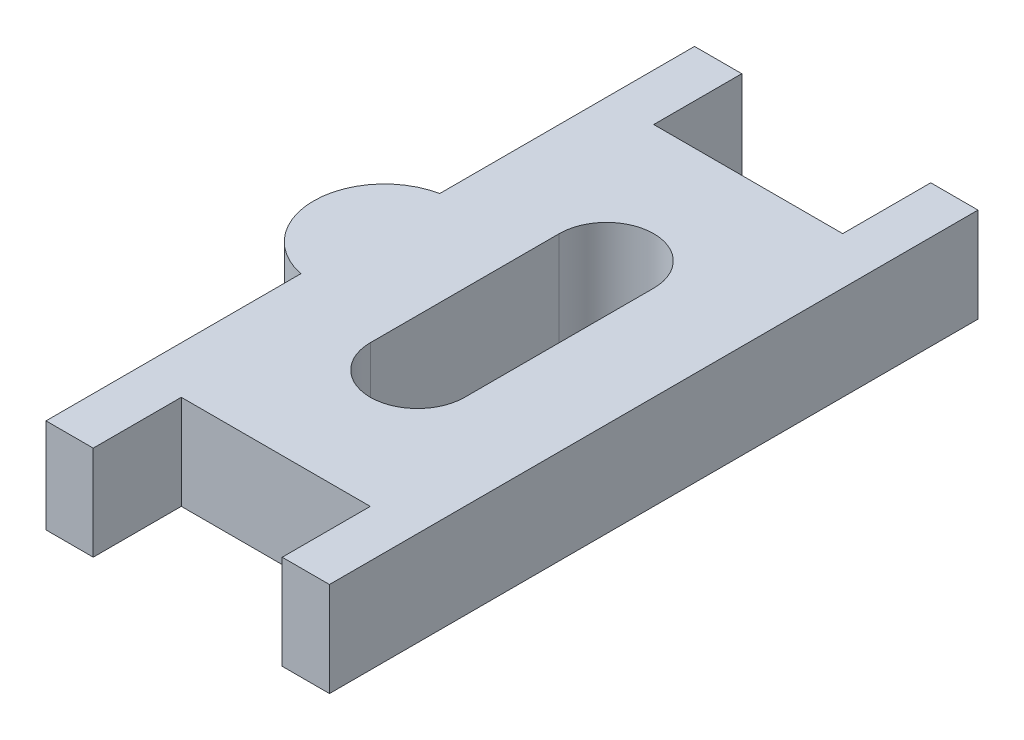
from build123d import *

# Parameters (mm, degrees)
BOSS_EXTRUDE1_DEPTH = 3.175
CUT_EXTRUDE1_REACH  = 5.175


with BuildPart() as part:
    # Sketch2 → Boss-Extrude1 (new body)
    with BuildSketch(Plane(origin=(0, 0, 0), x_dir=(1, 0, 0), z_dir=(0, 1, 0))):
        with BuildLine():
            Line((-3.175, 10.8966), (-3.175, 7.9375))
            Line((-3.175, 7.9375), (3.175, 7.9375))
            Line((3.175, 7.9375), (3.175, 10.8966))
            Line((3.175, 10.8966), (4.7625, 10.8966))
            Line((4.7625, 10.8966), (4.7625, -10.8966))
            Line((4.7625, -10.8966), (3.175, -10.8966))
            Line((3.175, -10.8966), (3.175, -7.9375))
            Line((3.175, -7.9375), (-3.175, -7.9375))
            Line((-3.175, -7.9375), (-3.175, -10.8966))
            Line((-3.175, -10.8966), (-4.7625, -10.8966))
            Line((-4.7625, -10.8966), (-4.7625, -2.33313898))
            ThreePointArc((-4.7625, -2.33313898), (-6.6675, 0), (-4.7625, 2.33313898))
            Line((-4.7625, 2.33313898), (-4.7625, 10.8966))
            Line((-4.7625, 10.8966), (-3.175, 10.8966))
        make_face()
    extrude(amount=BOSS_EXTRUDE1_DEPTH)

    # Sketch3 → Cut-Extrude1 (cut, up to next)
    with BuildSketch(Plane(origin=(0, 3.175, 0), x_dir=(1, 0, 0), z_dir=(0, 1, 0)), mode=Mode.PRIVATE) as cut_extrude1_sk1:
        with BuildLine():
            Line((1.5875, 3.175), (1.5875, -3.175))
            ThreePointArc((1.5875, -3.175), (0, -4.7625), (-1.5875, -3.175))
            Line((-1.5875, -3.175), (-1.5875, 3.175))
            ThreePointArc((-1.5875, 3.175), (0, 4.7625), (1.5875, 3.175))
        make_face()
    cut_extrude1_tool1 = extrude(cut_extrude1_sk1.sketch, amount=-CUT_EXTRUDE1_REACH, mode=Mode.PRIVATE) & part.part
    add(cut_extrude1_tool1.solids().sort_by_distance((0, 3.175, 0))[0], mode=Mode.SUBTRACT)


solid = part.part
